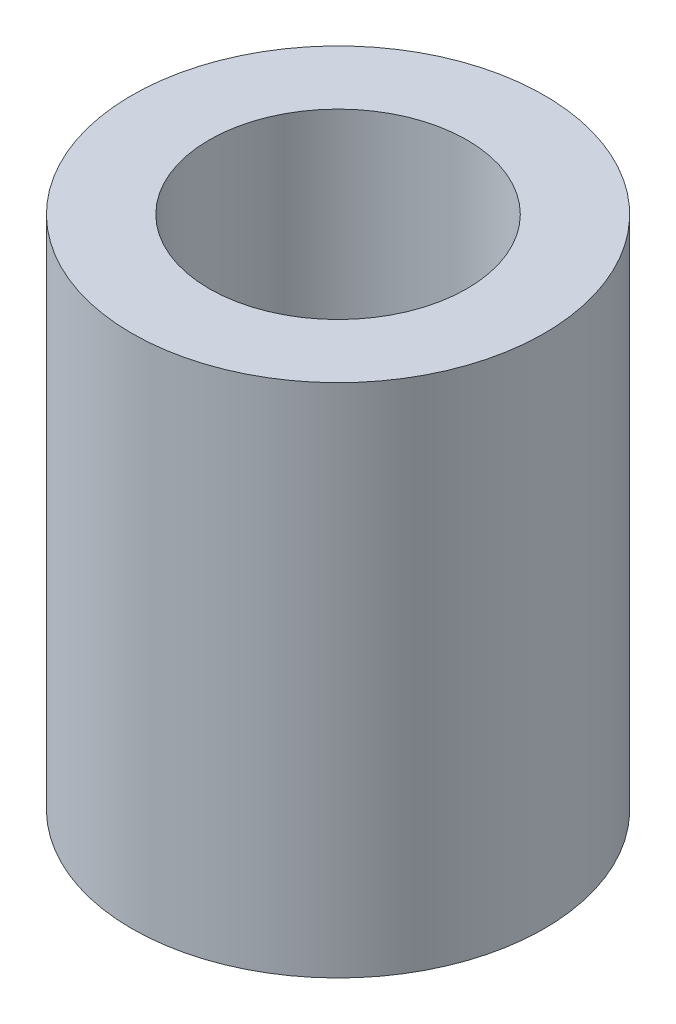
from build123d import *

# Parameters (mm, degrees)
SKETCH1_R           = 5.08
BOSS_EXTRUDE1_DEPTH = 12.7
SKETCH2_R           = 3.175
CUT_EXTRUDE1_DEPTH  = 13.7


with BuildPart() as part:
    # Sketch1 → Boss-Extrude1 (new body)
    with BuildSketch(Plane(origin=(0, 0, 0), x_dir=(1, 0, 0), z_dir=(0, 1, 0))):
        Circle(SKETCH1_R)
    extrude(amount=BOSS_EXTRUDE1_DEPTH)

    # Sketch2 → Cut-Extrude1 (cut, through all)
    with BuildSketch(Plane.XZ):
        Circle(SKETCH2_R)
    extrude(amount=-CUT_EXTRUDE1_DEPTH, mode=Mode.SUBTRACT)


solid = part.part
